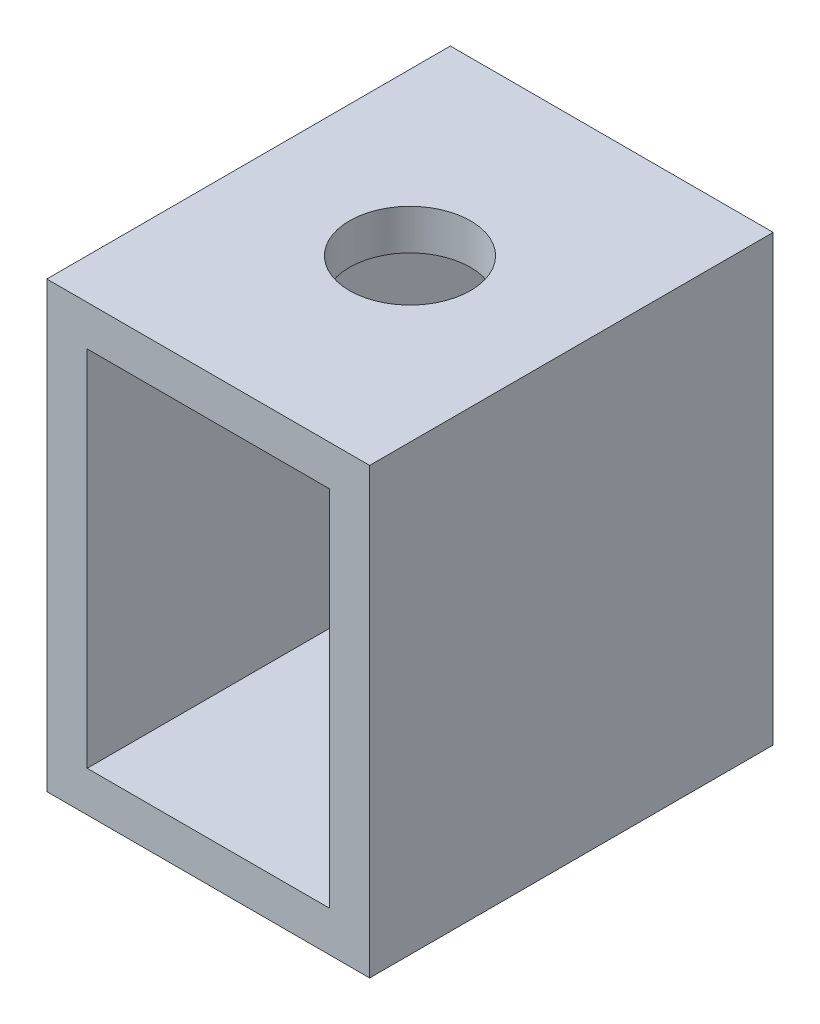
from build123d import *

# Parameters (mm, degrees)
SKETCH1_W           = 4
SKETCH1_H           = 5.5
SKETCH1_W_2         = 3
SKETCH1_H_2         = 4.5
EXTRUDE_THIN1_DEPTH = 5
CUT_EXTRUDE1_REACH  = 7.5
SKETCH2_R           = 0.75


with BuildPart() as part:
    # Sketch1 → Extrude-Thin1 (new body)
    with BuildSketch(Plane.XY):
        with Locations((1.5, 2.25)):
            Rectangle(SKETCH1_W, SKETCH1_H)
        with Locations((1.5, 2.25)):
            Rectangle(SKETCH1_W_2, SKETCH1_H_2, mode=Mode.SUBTRACT)
    extrude(amount=EXTRUDE_THIN1_DEPTH)

    # Sketch2 → Cut-Extrude1 (cut, up to next)
    with BuildSketch(Plane(origin=(0, 5, 0), x_dir=(1, 0, 0), z_dir=(0, 1, 0)), mode=Mode.PRIVATE) as cut_extrude1_sk1:
        with Locations((1.5, -2.5)):
            Circle(SKETCH2_R)
    cut_extrude1_tool1 = extrude(cut_extrude1_sk1.sketch, amount=-CUT_EXTRUDE1_REACH, mode=Mode.PRIVATE) & part.part
    add(cut_extrude1_tool1.solids().sort_by_distance((1.5, 5, 2.5))[0], mode=Mode.SUBTRACT)


solid = part.part
